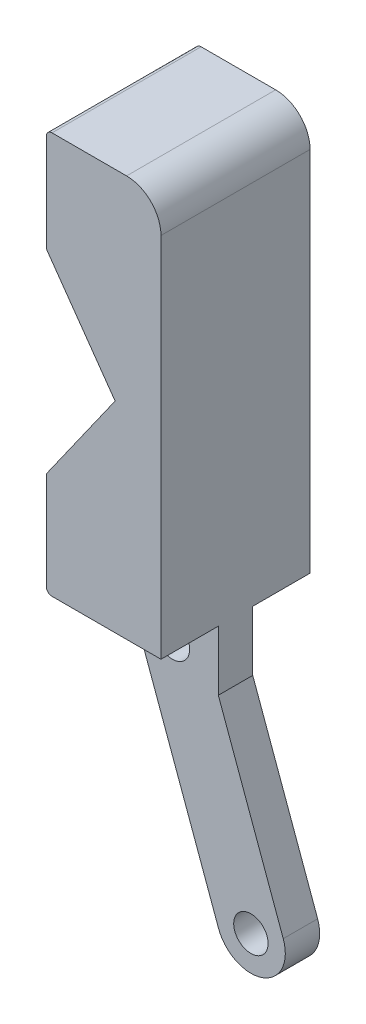
from build123d import *

# Parameters (mm, degrees)
ESTRUSIONE_ESTRUSIONE1_DEPTH      = 1.5
ESTRUSIONE_ESTRUSIONE1_DEPTH_BACK = 1.5
SCHIZZO2_R                        = 1.5
ESTRUSIONE_ESTRUSIONE2_DEPTH      = 6.5
ESTRUSIONE_ESTRUSIONE2_DEPTH_BACK = 6.5
RACCORDO1_R                       = 3
RACCORDO2_R                       = 0.5
RACCORDO3_R                       = 0.5


with BuildPart() as part:
    # Schizzo2 → Estrusione-Estrusione1 (new, two sides: drawn at the far end of the back side and taken through both)
    with BuildSketch(Plane.XY.offset(-ESTRUSIONE_ESTRUSIONE1_DEPTH_BACK)):
        with BuildLine():
            Line((-9.659480729, 17.767791986), (-2.819077862, -1.02606043))
            ThreePointArc((-2.819077862, -1.02606043), (1.02606043, -2.819077862), (2.819077862, 1.02606043))
            Line((2.819077862, 1.02606043), (-2.840402867, 16.575355938))
            Line((-2.840402867, 16.575355938), (-2.840402867, 21.793852416))
            Line((-2.840402867, 21.793852416), (-10.348829971, 21.793852416))
            Line((-10.348829971, 21.793852416), (-9.840402867, 18.793852416))
            ThreePointArc((-9.840402867, 18.793852416), (-9.794826126, 18.272907883), (-9.659480729, 17.767791986))
        make_face()
        with Locations((-6.840402867, 18.793852416)):
            Circle(SCHIZZO2_R, mode=Mode.SUBTRACT)
        Circle(SCHIZZO2_R, mode=Mode.SUBTRACT)
    extrude(amount=ESTRUSIONE_ESTRUSIONE1_DEPTH + ESTRUSIONE_ESTRUSIONE1_DEPTH_BACK)

    # Schizzo2_10 → Estrusione-Estrusione2 (add, two sides: drawn at the far end of the back side and taken through both)
    with BuildSketch(Plane.XY.offset(-ESTRUSIONE_ESTRUSIONE2_DEPTH_BACK)):
        Polygon((-12.840402867, 21.793852416), (-10.348829971, 21.793852416), (-6.840402867, 21.793852416), (-2.840402867, 21.793852416), (-2.840402867, 56.793852416), (-12.840402867, 56.793852416), (-12.840402867, 47.793852416), (-6.840402867, 39.293852416), (-12.840402867, 30.793852416), align=None)
    extrude(amount=ESTRUSIONE_ESTRUSIONE2_DEPTH + ESTRUSIONE_ESTRUSIONE2_DEPTH_BACK)

    # Raccordo1
    raccordo1_edges = [part.edges().sort_by_distance(p)[0] for p in [
        (-2.840402867, 56.793852416, 0),
    ]]
    fillet(raccordo1_edges, radius=RACCORDO1_R)

    # Raccordo2
    raccordo2_edges = [part.edges().sort_by_distance(p)[0] for p in [
        (-12.840402867, 21.793852416, 0),
    ]]
    fillet(raccordo2_edges, radius=RACCORDO2_R)

    # Raccordo3
    raccordo3_edges = [part.edges().sort_by_distance(p)[0] for p in [
        (-12.840402867, 56.793852416, 0),
    ]]
    fillet(raccordo3_edges, radius=RACCORDO3_R)


solid = part.part
